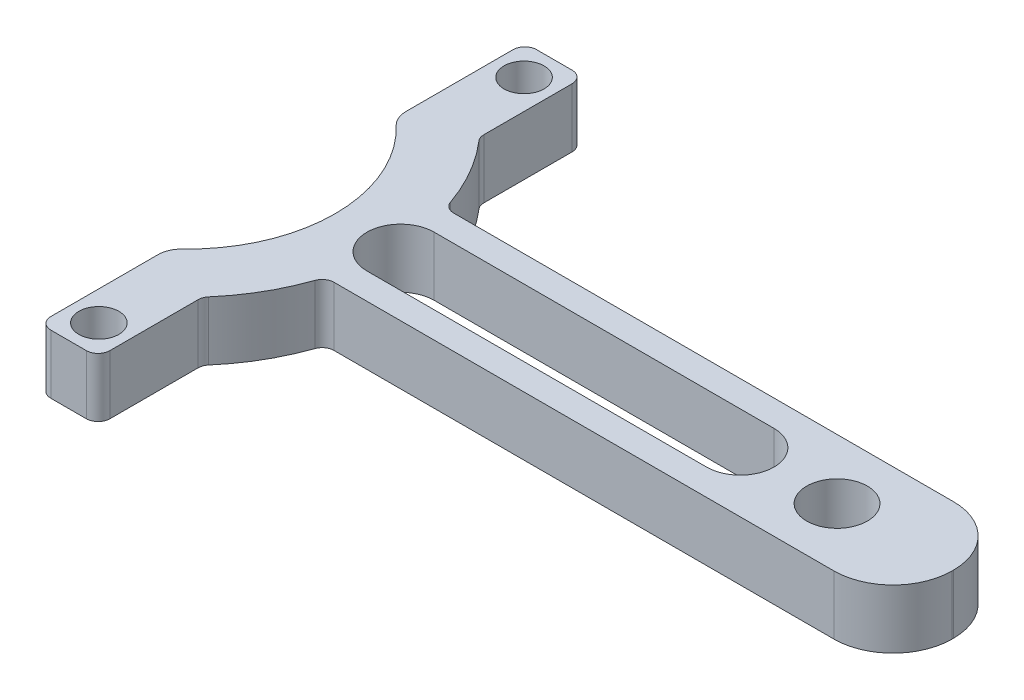
from build123d import *

# Parameters (mm, degrees)
SKETCH1_R                = 22.225
SKETCH1_R_2              = 15.875
BOSS_EXTRUDE1_DEPTH      = 6.35
BOSS_EXTRUDE2_DEPTH      = 6.35
F_0_257_DIAMETER_HOLE1_D = 6.5278
SKETCH6_W                = 65.552410467
SKETCH6_H                = 82.171101747
CUT_EXTRUDE2_DEPTH       = 7.35
FILLET2_R                = 2.54
SKETCH9_R                = 2.15265
BOSS_EXTRUDE3_DEPTH      = 6.35
FILLET4_R                = 1.27
CUT_EXTRUDE3_DEPTH       = 7.35


with BuildPart() as part:
    # Sketch1 → Boss-Extrude1 (new body)
    with BuildSketch(Plane(origin=(0, 0, 0), x_dir=(1, 0, 0), z_dir=(0, 1, 0))):
        Circle(SKETCH1_R)
        Circle(SKETCH1_R_2, mode=Mode.SUBTRACT)
    extrude(amount=BOSS_EXTRUDE1_DEPTH)

    # Sketch2 → Boss-Extrude2 (add)
    with BuildSketch(Plane(origin=(0, 6.35, 0), x_dir=(1, 0, 0), z_dir=(0, 1, 0))):
        with BuildLine():
            Line((75.953359527, -6.4389), (38.518839527, -6.4389))
            Line((38.518839527, -6.4389), (17.590769706, -6.4389))
            Line((17.590769706, -6.4389), (17.590769706, 6.4389))
            Line((17.590769706, 6.4389), (38.518839527, 6.4389))
            Line((38.518839527, 6.4389), (75.953359527, 6.4389))
            ThreePointArc((75.953359527, 6.4389), (80.443487588, 4.579028061), (82.303359527, 0.0889))
            Line((82.303359527, 0.0889), (82.303359527, -0.0889))
            ThreePointArc((82.303359527, -0.0889), (80.443487588, -4.579028061), (75.953359527, -6.4389))
        make_face()
    extrude(amount=-BOSS_EXTRUDE2_DEPTH)

    # F (0.257) Diameter Hole1 (through all)
    with Locations(Plane(origin=(0, 6.35, 0), x_dir=(1, 0, 0), z_dir=(0, 1, 0))):
        with Locations((69.85, 0)):
            Hole(F_0_257_DIAMETER_HOLE1_D / 2)

    # Sketch6 → Cut-Extrude2 (cut, through all)
    with BuildSketch(Plane(origin=(0, 6.35, 0), x_dir=(1, 0, 0), z_dir=(0, 1, 0))):
        with Locations((-22.616205234, -1.153387837)):
            Rectangle(SKETCH6_W, SKETCH6_H)
    extrude(amount=-CUT_EXTRUDE2_DEPTH, mode=Mode.SUBTRACT)

    # Fillet2
    fillet2_edges = [part.edges().sort_by_distance(p)[0] for p in [
        (10.16, 3.175, -12.197951672),
        (10.16, 3.175, 12.197951672),
    ]]
    fillet(fillet2_edges, radius=FILLET2_R)

    # Sketch9 → Boss-Extrude3 (add)
    with BuildSketch(Plane(origin=(0, 6.35, 0), x_dir=(1, 0, 0), z_dir=(0, 1, 0))):
        Polygon((10.16, 19.766765669), (10.16, 26.116765669), (16.51, 26.116765669), (16.51, 14.878525633), align=None)
        with Locations((13.335, 22.86)):
            Circle(SKETCH9_R, mode=Mode.SUBTRACT)
    boss_extrude3 = extrude(amount=-BOSS_EXTRUDE3_DEPTH)

    # Mirror1: Boss-Extrude3 across plane
    add(boss_extrude3.mirror(Plane.XY))

    # Fillet4
    fillet4_edges = [part.edges().sort_by_distance(p)[0] for p in [
        (21.271840348, 3.175, 6.4389),
        (21.271840348, 3.175, -6.4389),
        (16.51, 3.175, 14.878525633),
        (16.51, 3.175, 26.116765669),
        (10.16, 3.175, 26.116765669),
        (16.51, 3.175, -14.878525633),
        (10.16, 3.175, -26.116765669),
        (16.51, 3.175, -26.116765669),
    ]]
    fillet(fillet4_edges, radius=FILLET4_R)

    # Sketch11 → Cut-Extrude3 (cut, through all)
    with BuildSketch(Plane(origin=(0, 6.35, 0), x_dir=(1, 0, 0), z_dir=(0, 1, 0))):
        with BuildLine():
            Line((59.445816997, -3.615471241), (22.916160789, -3.615471241))
            ThreePointArc((22.916160789, -3.615471241), (19.300689548, 0), (22.916160789, 3.615471241))
            Line((22.916160789, 3.615471241), (59.445816997, 3.615471241))
            ThreePointArc((59.445816997, 3.615471241), (63.061288238, 0), (59.445816997, -3.615471241))
        make_face()
    extrude(amount=-CUT_EXTRUDE3_DEPTH, mode=Mode.SUBTRACT)


solid = part.part
